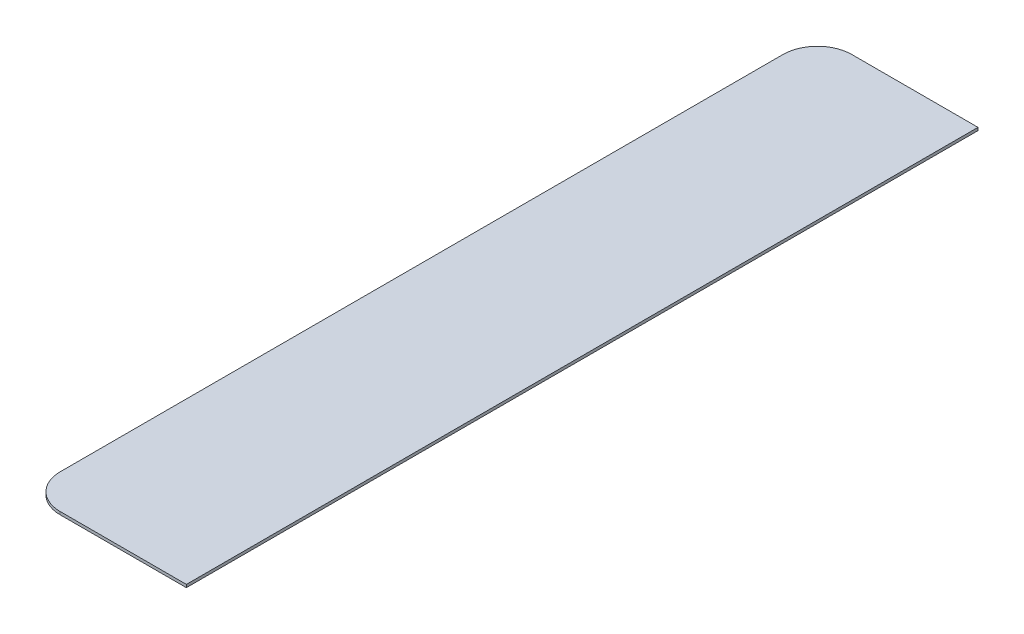
from build123d import *

# Parameters (mm, degrees)
BOSS_EXTRUDE1_DEPTH = 6.35


with BuildPart() as part:
    # Sketch1 → Boss-Extrude1 (new body)
    with BuildSketch(Plane(origin=(0, 0, 0), x_dir=(1, 0, 0), z_dir=(0, 1, 0))):
        with BuildLine():
            Line((0, 0), (-279.4, 0))
            ThreePointArc((-279.4, 0), (-333.281536726, -22.318463274), (-355.6, -76.2))
            Line((-355.6, -76.2), (-355.6, -1676.4))
            ThreePointArc((-355.6, -1676.4), (-333.281536726, -1730.281536726), (-279.4, -1752.6))
            Line((-279.4, -1752.6), (0, -1752.6))
            Line((0, -1752.6), (0, 0))
        make_face()
    extrude(amount=BOSS_EXTRUDE1_DEPTH)


solid = part.part
